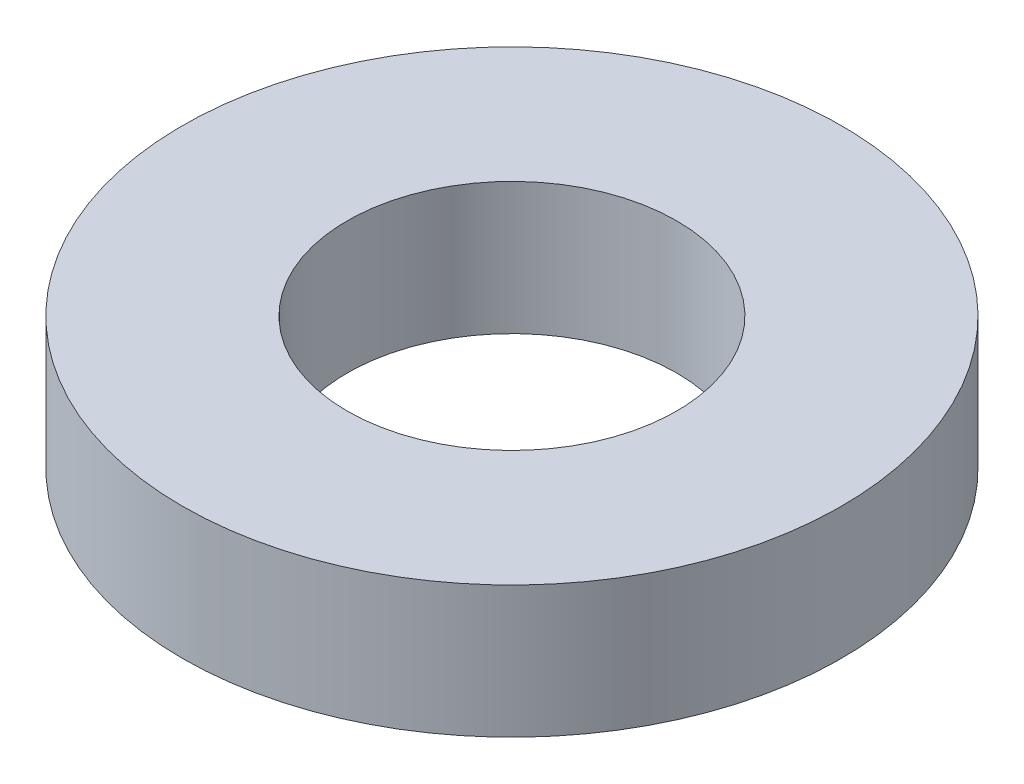
from build123d import *

# Parameters (mm, degrees)
CROQUIS1_R              = 5
CROQUIS1_R_2            = 2.5
SALIENTE_EXTRUIR1_DEPTH = 2


with BuildPart() as part:
    # Croquis1 → Saliente-Extruir1 (new body)
    with BuildSketch(Plane(origin=(0, 0, 0), x_dir=(1, 0, 0), z_dir=(0, 1, 0))):
        Circle(CROQUIS1_R)
        Circle(CROQUIS1_R_2, mode=Mode.SUBTRACT)
    extrude(amount=SALIENTE_EXTRUIR1_DEPTH)


solid = part.part
